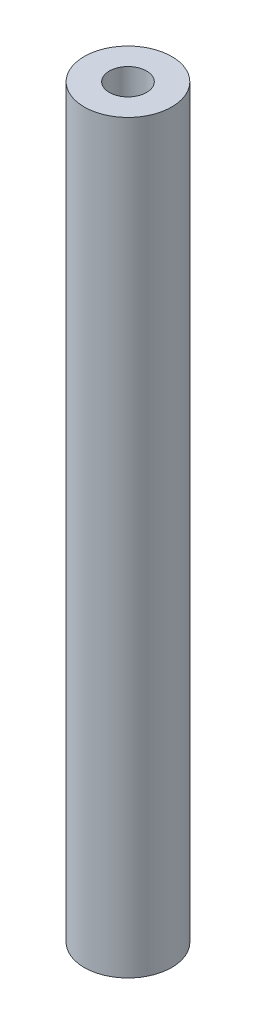
from build123d import *

# Parameters (mm, degrees)
SKETCH1_R           = 2.055
SKETCH1_R_2         = 0.875
BOSS_EXTRUDE1_DEPTH = 17.5


with BuildPart() as part:
    # Sketch1 → Boss-Extrude1 (new body, symmetric)
    with BuildSketch(Plane(origin=(0, 0, 0), x_dir=(1, 0, 0), z_dir=(0, 1, 0))):
        Circle(SKETCH1_R)
        Circle(SKETCH1_R_2, mode=Mode.SUBTRACT)
    extrude(amount=BOSS_EXTRUDE1_DEPTH, both=True)


solid = part.part
